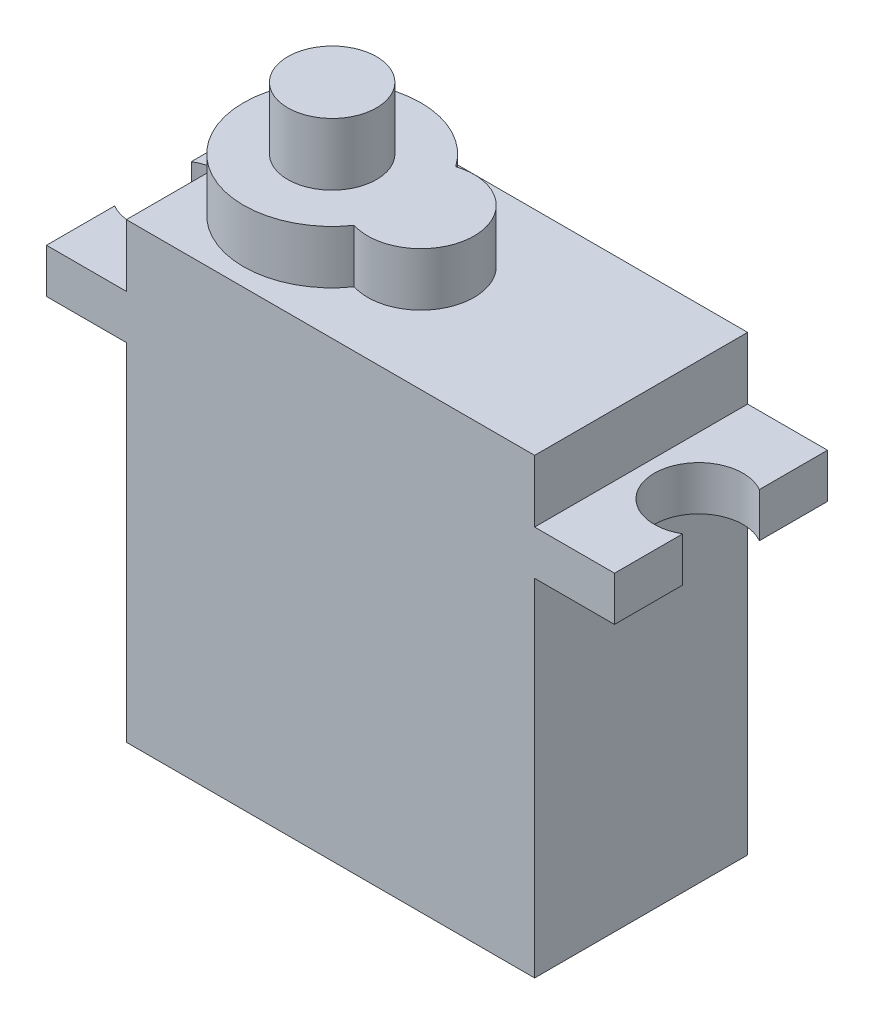
from build123d import *

# Parameters (mm, degrees)
CROQUIS1_W                 = 23
CROQUIS1_H                 = 12
SALIENTE_EXTRUIR1_DEPTH    = 19.5
CROQUIS2_W                 = 32
CROQUIS2_H                 = 12
SALIENTE_EXTRUIR2_DEPTH    = 2.5
CROQUIS3_W                 = 23
CROQUIS3_H                 = 12
SALIENTE_EXTRUIR3_DEPTH    = 3.5
CORTAR_EXTRUIR1_DEPTH      = 4.5
CORTAR_EXTRUIR1_DEPTH_BACK = 23
SALIENTE_EXTRUIR4_DEPTH    = 3
CROQUIS6_R                 = 2.5
SALIENTE_EXTRUIR5_DEPTH    = 3.5


with BuildPart() as part:
    # Croquis1 → Saliente-Extruir1 (new body)
    with BuildSketch(Plane(origin=(0, 0, 0), x_dir=(1, 0, 0), z_dir=(0, 1, 0))):
        Rectangle(CROQUIS1_W, CROQUIS1_H)
    extrude(amount=SALIENTE_EXTRUIR1_DEPTH)

    # Croquis2 → Saliente-Extruir2 (add)
    with BuildSketch(Plane(origin=(0, 19.5, 0), x_dir=(1, 0, 0), z_dir=(0, 1, 0))):
        Rectangle(CROQUIS2_W, CROQUIS2_H)
    extrude(amount=SALIENTE_EXTRUIR2_DEPTH)

    # Croquis3 → Saliente-Extruir3 (add)
    with BuildSketch(Plane(origin=(0, 22, 0), x_dir=(1, 0, 0), z_dir=(0, 1, 0))):
        Rectangle(CROQUIS3_W, CROQUIS3_H)
    extrude(amount=SALIENTE_EXTRUIR3_DEPTH)

    # Croquis4 → Cortar-Extruir1 (cut, two sides)
    with BuildSketch(Plane(origin=(0, 22, 0), x_dir=(1, 0, 0), z_dir=(0, 1, 0))) as cortar_extruir1_sk:
        with BuildLine():
            Line((-16, 2.161008353), (-16, -2.161008353))
            ThreePointArc((-16, -2.161008353), (-12.243002427, 0), (-16, 2.161008353))
        make_face()
        with BuildLine():
            Line((16, 2.161008353), (16, -2.161008353))
            ThreePointArc((16, -2.161008353), (12.243002427, 0), (16, 2.161008353))
        make_face()
    extrude(amount=CORTAR_EXTRUIR1_DEPTH, mode=Mode.SUBTRACT)
    extrude(cortar_extruir1_sk.sketch, amount=-CORTAR_EXTRUIR1_DEPTH_BACK, mode=Mode.SUBTRACT)

    # Croquis5 → Saliente-Extruir4 (add)
    with BuildSketch(Plane(origin=(0, 25.5, 0), x_dir=(1, 0, 0), z_dir=(0, 1, 0))):
        with BuildLine():
            ThreePointArc((-1.805877758, 2.861817604), (-10.905877758, 0), (-1.805877758, -2.861817604))
            ThreePointArc((-1.805877758, -2.861817604), (2.094122242, 0), (-1.805877758, 2.861817604))
        make_face()
    extrude(amount=SALIENTE_EXTRUIR4_DEPTH)

    # Croquis6 → Saliente-Extruir5 (add)
    with BuildSketch(Plane(origin=(0, 28.5, 0), x_dir=(1, 0, 0), z_dir=(0, 1, 0))):
        with Locations((-5.905877758, 0)):
            Circle(CROQUIS6_R)
    extrude(amount=SALIENTE_EXTRUIR5_DEPTH)


solid = part.part
